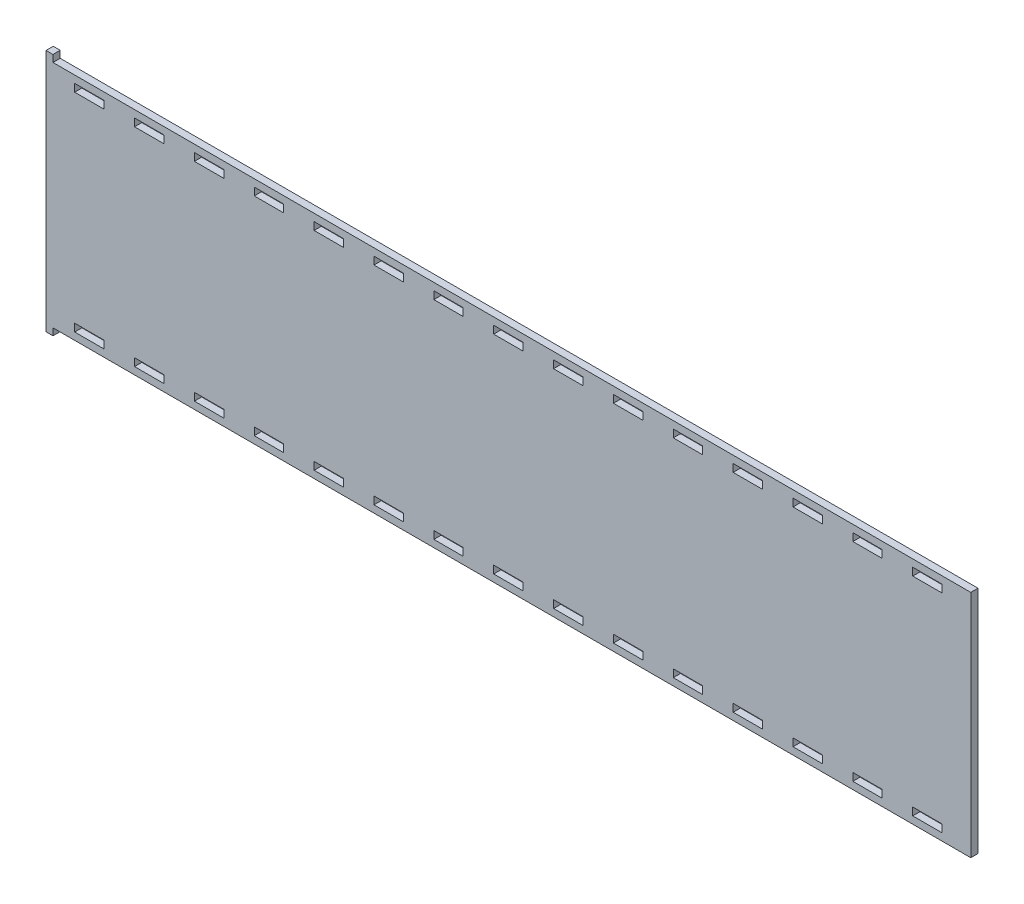
from build123d import *

# Parameters (mm, degrees)
SKETCH1_W           = 12.9
SKETCH1_H           = 3.3782
BOSS_EXTRUDE1_DEPTH = 3.175


with BuildPart() as part:
    # Sketch1 → Boss-Extrude1 (new body)
    with BuildSketch(Plane.XY):
        Polygon((3.0496002, 100.7618), (0, 100.7618), (0, -6.3246), (3.0496002, -6.3246), (3.0496002, -3.2782), (406.4, -3.2782), (406.4, 97.7154), (3.0496002, 97.7154), align=None)
        with Locations((19.05, 92.8513)):
            Rectangle(SKETCH1_W, SKETCH1_H, mode=Mode.SUBTRACT)
        with Locations((45.357142857, 92.8513)):
            Rectangle(SKETCH1_W, SKETCH1_H, mode=Mode.SUBTRACT)
        with Locations((387.35, 92.8513)):
            Rectangle(SKETCH1_W, SKETCH1_H, mode=Mode.SUBTRACT)
        with Locations((361.042857143, 92.8513)):
            Rectangle(SKETCH1_W, SKETCH1_H, mode=Mode.SUBTRACT)
        with Locations((71.664285714, 92.8513)):
            Rectangle(SKETCH1_W, SKETCH1_H, mode=Mode.SUBTRACT)
        with Locations((97.971428571, 92.8513)):
            Rectangle(SKETCH1_W, SKETCH1_H, mode=Mode.SUBTRACT)
        with Locations((124.278571429, 92.8513)):
            Rectangle(SKETCH1_W, SKETCH1_H, mode=Mode.SUBTRACT)
        with Locations((150.585714286, 92.8513)):
            Rectangle(SKETCH1_W, SKETCH1_H, mode=Mode.SUBTRACT)
        with Locations((176.892857143, 92.8513)):
            Rectangle(SKETCH1_W, SKETCH1_H, mode=Mode.SUBTRACT)
        with Locations((203.2, 92.8513)):
            Rectangle(SKETCH1_W, SKETCH1_H, mode=Mode.SUBTRACT)
        with Locations((229.507142857, 92.8513)):
            Rectangle(SKETCH1_W, SKETCH1_H, mode=Mode.SUBTRACT)
        with Locations((255.814285714, 92.8513)):
            Rectangle(SKETCH1_W, SKETCH1_H, mode=Mode.SUBTRACT)
        with Locations((282.121428571, 92.8513)):
            Rectangle(SKETCH1_W, SKETCH1_H, mode=Mode.SUBTRACT)
        with Locations((308.428571429, 92.8513)):
            Rectangle(SKETCH1_W, SKETCH1_H, mode=Mode.SUBTRACT)
        with Locations((334.735714286, 92.8513)):
            Rectangle(SKETCH1_W, SKETCH1_H, mode=Mode.SUBTRACT)
        with Locations((387.35, 1.5859)):
            Rectangle(SKETCH1_W, SKETCH1_H, mode=Mode.SUBTRACT)
        with Locations((361.042857143, 1.5859)):
            Rectangle(SKETCH1_W, SKETCH1_H, mode=Mode.SUBTRACT)
        with Locations((334.735714286, 1.5859)):
            Rectangle(SKETCH1_W, SKETCH1_H, mode=Mode.SUBTRACT)
        with Locations((308.428571429, 1.5859)):
            Rectangle(SKETCH1_W, SKETCH1_H, mode=Mode.SUBTRACT)
        with Locations((282.121428571, 1.5859)):
            Rectangle(SKETCH1_W, SKETCH1_H, mode=Mode.SUBTRACT)
        with Locations((255.814285714, 1.5859)):
            Rectangle(SKETCH1_W, SKETCH1_H, mode=Mode.SUBTRACT)
        with Locations((229.507142857, 1.5859)):
            Rectangle(SKETCH1_W, SKETCH1_H, mode=Mode.SUBTRACT)
        with Locations((203.2, 1.5859)):
            Rectangle(SKETCH1_W, SKETCH1_H, mode=Mode.SUBTRACT)
        with Locations((176.892857143, 1.5859)):
            Rectangle(SKETCH1_W, SKETCH1_H, mode=Mode.SUBTRACT)
        with Locations((150.585714286, 1.5859)):
            Rectangle(SKETCH1_W, SKETCH1_H, mode=Mode.SUBTRACT)
        with Locations((124.278571429, 1.5859)):
            Rectangle(SKETCH1_W, SKETCH1_H, mode=Mode.SUBTRACT)
        with Locations((97.971428571, 1.5859)):
            Rectangle(SKETCH1_W, SKETCH1_H, mode=Mode.SUBTRACT)
        with Locations((71.664285714, 1.5859)):
            Rectangle(SKETCH1_W, SKETCH1_H, mode=Mode.SUBTRACT)
        with Locations((45.357142857, 1.5859)):
            Rectangle(SKETCH1_W, SKETCH1_H, mode=Mode.SUBTRACT)
        with Locations((19.05, 1.5859)):
            Rectangle(SKETCH1_W, SKETCH1_H, mode=Mode.SUBTRACT)
    extrude(amount=BOSS_EXTRUDE1_DEPTH)


solid = part.part
